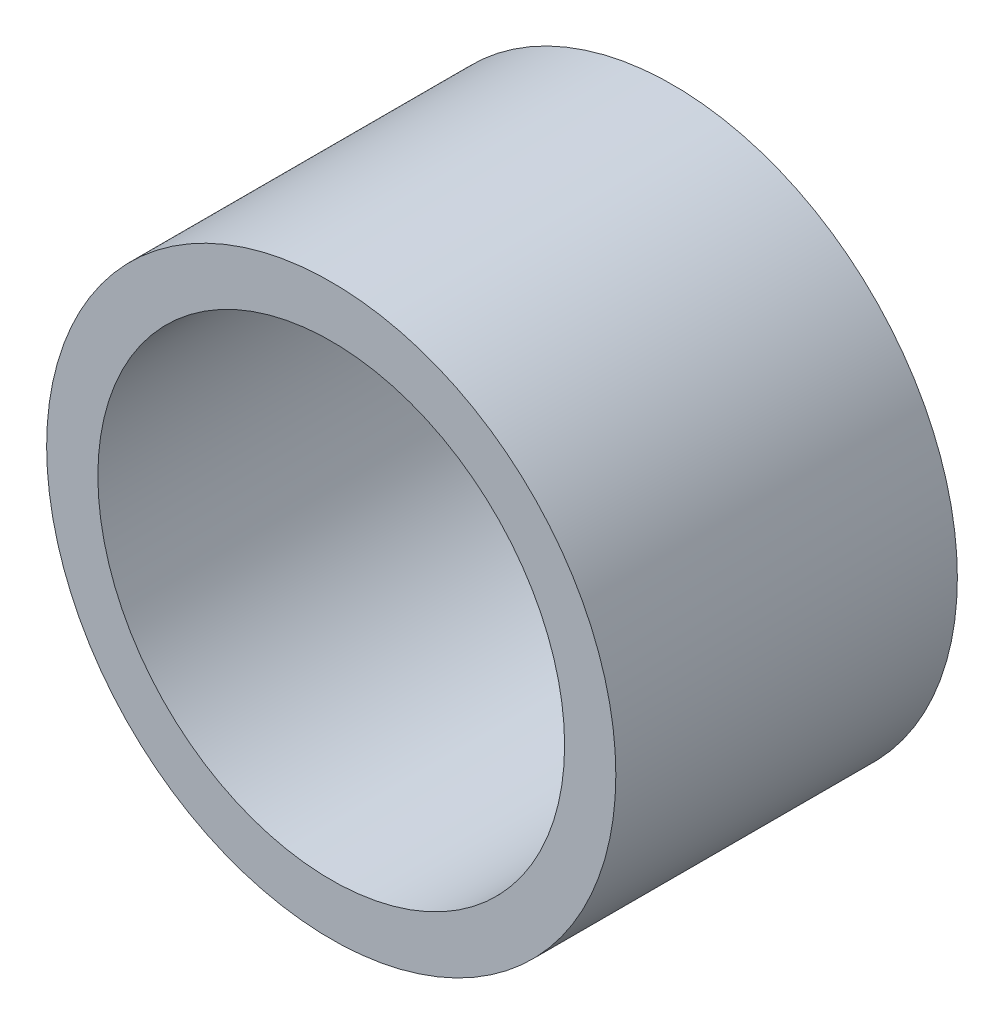
from build123d import *

# Parameters (mm, degrees)
SKETCH_1_R      = 25
SKETCH_1_R_2    = 20.5
EXTRUDE_1_DEPTH = 30


with BuildPart() as part:
    # 草图1 → 凸台-拉伸1 (new body)
    with BuildSketch(Plane.XY):
        with Locations((69.89048691, -10.025166497)):
            Circle(SKETCH_1_R)
        with Locations((69.89048691, -10.025166497)):
            Circle(SKETCH_1_R_2, mode=Mode.SUBTRACT)
    extrude(amount=EXTRUDE_1_DEPTH)


solid = part.part
